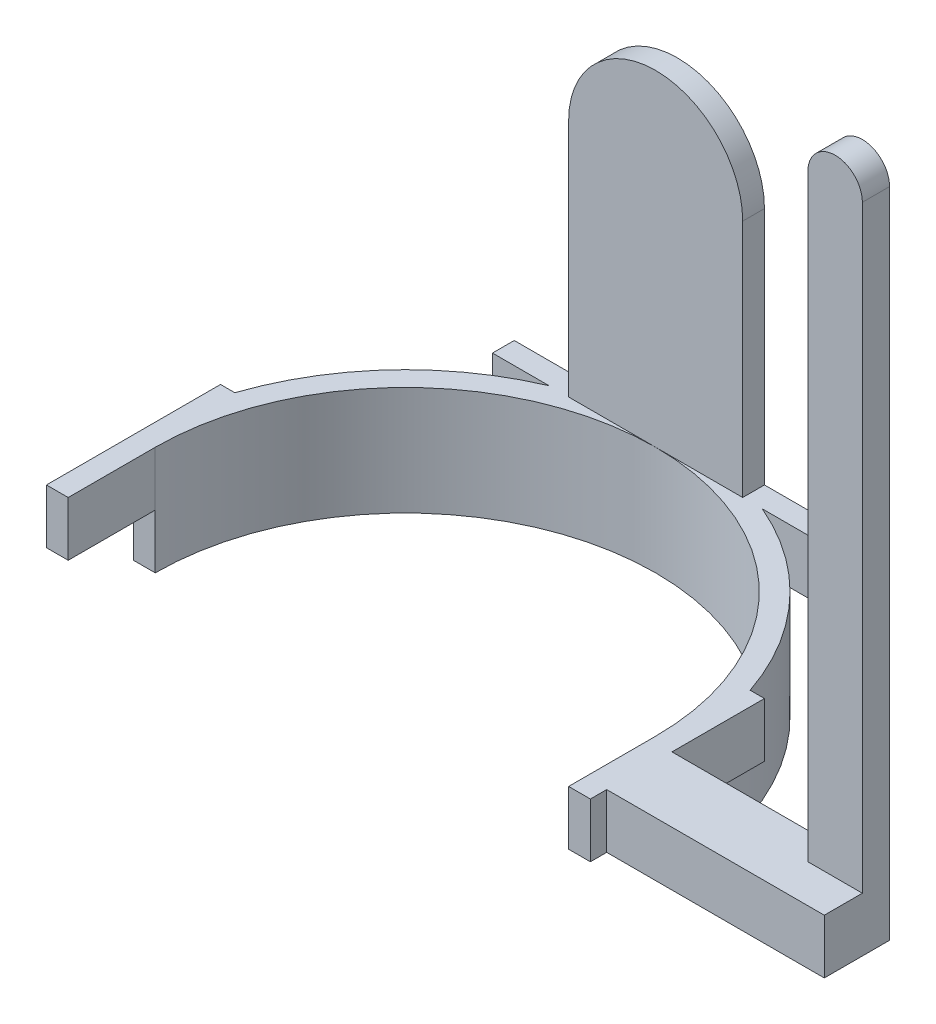
from build123d import *

# Parameters (mm, degrees)
EXTRUDE_1_DEPTH     = 10
EXTRUDE_2_DEPTH     = 10
SKETCH_4_W          = 32
SKETCH_4_H          = 4
EXTRUDE_3_DEPTH     = 60
CUT_EXTRUDE_1_DEPTH = 30
SKETCH_6_W          = 12
SKETCH_6_H          = 10
EXTRUDE_4_DEPTH     = 40
SKETCH_7_W          = 10
SKETCH_7_H          = 5
EXTRUDE_5_DEPTH     = 110
SKETCH_8_R          = 5
EXTRUDE_6_DEPTH     = 5


with BuildPart() as part:
    # 草图1 → 凸台-拉伸1 (new body)
    with BuildSketch(Plane(origin=(0, 0, 0), x_dir=(1, 0, 0), z_dir=(0, 1, 0))):
        with BuildLine():
            Line((-50, 0), (-46, 0))
            ThreePointArc((-46, 0), (0, 46), (46, 0))
            Line((46, 0), (50, 0))
            ThreePointArc((50, 0), (0, 50), (-50, 0))
        make_face()
    extrude(amount=EXTRUDE_1_DEPTH)

    # 草图3 → 凸台-拉伸2 (add)
    with BuildSketch(Plane(origin=(0, 10, 0), x_dir=(1, 0, 0), z_dir=(0, 1, 0))):
        with BuildLine():
            Line((-50, 16), (-47.370877129, 16))
            ThreePointArc((-47.370877129, 16), (-36.689752119, 33.968545589), (-19.595917942, 46))
            Line((-19.595917942, 46), (-30, 46))
            Line((-30, 46), (-30, 50))
            Line((-30, 50), (30, 50))
            Line((30, 50), (30, 46))
            Line((30, 46), (19.595917942, 46))
            ThreePointArc((19.595917942, 46), (36.689752119, 33.968545589), (47.370877129, 16))
            Line((47.370877129, 16), (50, 16))
            Line((50, 16), (50, -16))
            Line((50, -16), (46, -16))
            Line((46, -16), (46, 0))
            ThreePointArc((46, 0), (0, 46), (-46, 0))
            Line((-46, 0), (-46, -16))
            Line((-46, -16), (-50, -16))
            Line((-50, -16), (-50, 16))
        make_face()
    extrude(amount=EXTRUDE_2_DEPTH)

    # 草图4 → 凸台-拉伸3 (add)
    with BuildSketch(Plane(origin=(0, 20, 0), x_dir=(1, 0, 0), z_dir=(0, 1, 0))):
        with Locations((0, 48)):
            Rectangle(SKETCH_4_W, SKETCH_4_H)
    extrude(amount=EXTRUDE_3_DEPTH)

    # 草图5 → 切除-拉伸1 (cut)
    with BuildSketch(Plane(origin=(0, 0, -50), x_dir=(-1, 0, 0), z_dir=(0, 0, -1))):
        with BuildLine():
            Line((-16, 64), (-16, 97.905328476))
            Line((-16, 97.905328476), (16, 97.905328476))
            Line((16, 97.905328476), (16, 64))
            ThreePointArc((16, 64), (0, 80), (-16, 64))
        make_face()
    extrude(amount=-CUT_EXTRUDE_1_DEPTH, mode=Mode.SUBTRACT)

    # 草图6 → 凸台-拉伸4 (add)
    with BuildSketch(Plane(origin=(50, 0, 0), x_dir=(0, 0, -1), z_dir=(1, 0, 0))):
        with Locations((-7, 15)):
            Rectangle(SKETCH_6_W, SKETCH_6_H)
    extrude(amount=EXTRUDE_4_DEPTH)

    # 草图7 → 凸台-拉伸5 (add)
    with BuildSketch(Plane(origin=(0, 20, 0), x_dir=(1, 0, 0), z_dir=(0, 1, 0))):
        with Locations((85, -3.5)):
            Rectangle(SKETCH_7_W, SKETCH_7_H)
    extrude(amount=EXTRUDE_5_DEPTH)

    # 草图8 → 凸台-拉伸6 (add)
    with BuildSketch(Plane(origin=(0, 0, 1), x_dir=(-1, 0, 0), z_dir=(0, 0, -1))):
        with Locations((-85, 130)):
            Circle(SKETCH_8_R)
    extrude(amount=-EXTRUDE_6_DEPTH)


solid = part.part
